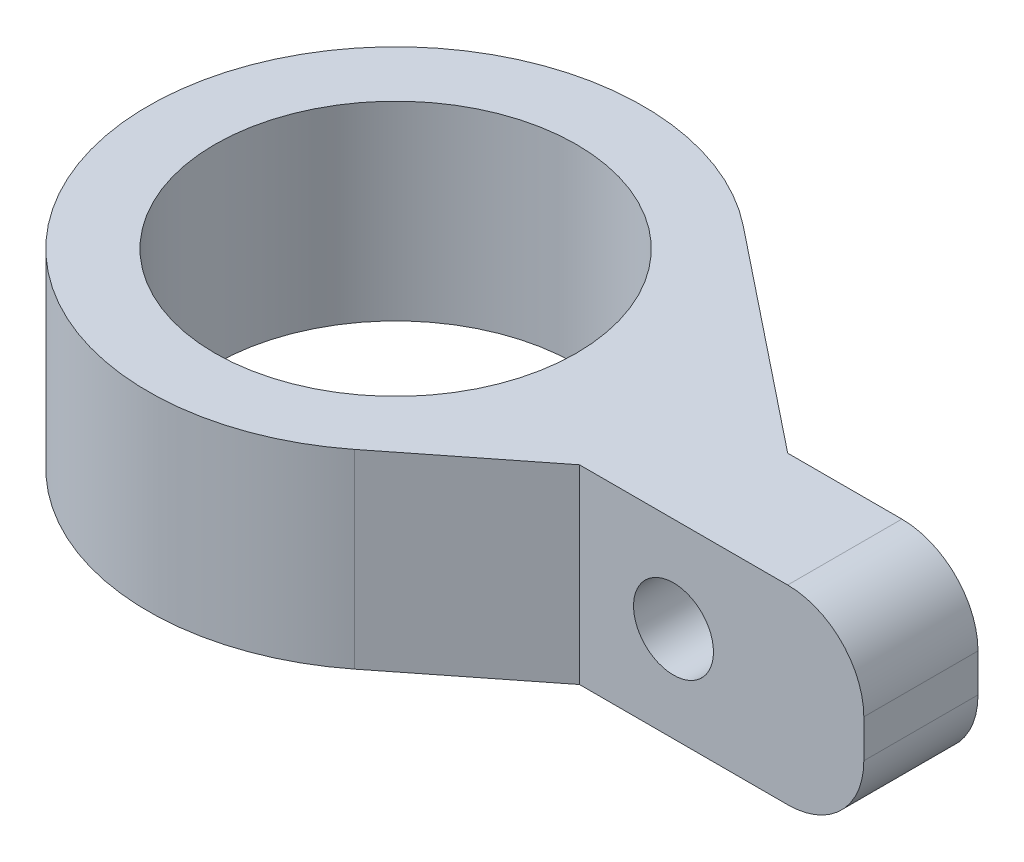
from build123d import *

# Parameters (mm, degrees)
SKETCH1_W           = 10
SKETCH1_H           = 5
BOSS_EXTRUDE1_DEPTH = 3
FILLET1_R           = 2
SKETCH3_R           = 6.5
BOSS_EXTRUDE2_DEPTH = 2.5
SKETCH4_R           = 4.75
CUT_EXTRUDE1_DEPTH  = 6
SKETCH7_R           = 1.05
CUT_EXTRUDE2_DEPTH  = 2
BOSS_EXTRUDE3_DEPTH = 5


with BuildPart() as part:
    # Sketch1 → Boss-Extrude1 (new body)
    with BuildSketch(Plane.XY):
        Rectangle(SKETCH1_W, SKETCH1_H)
    extrude(amount=BOSS_EXTRUDE1_DEPTH)

    # Fillet1
    fillet1_edges = [part.edges().sort_by_distance(p)[0] for p in [
        (5, 2.5, 1.5),
        (5, -2.5, 1.5),
    ]]
    fillet(fillet1_edges, radius=FILLET1_R)

    # Sketch7 → Cut-Extrude2 (cut)
    with BuildSketch(Plane.XY.offset(3)):
        Circle(SKETCH7_R)
    extrude(amount=-CUT_EXTRUDE2_DEPTH, mode=Mode.SUBTRACT)



with BuildPart() as body_2:
    # Sketch3 → Boss-Extrude2 (new body, symmetric)
    with BuildSketch(Plane(origin=(0, 0, 0), x_dir=(1, 0, 0), z_dir=(0, 1, 0))):
        with Locations((-9.8, -0.5)):
            Circle(SKETCH3_R)
    extrude(amount=BOSS_EXTRUDE2_DEPTH, both=True)

    # Sketch4 → Cut-Extrude1 (cut, through all)
    with BuildSketch(Plane.XZ.offset(2.5)):
        with Locations((-9.8, 0.5)):
            Circle(SKETCH4_R)
    extrude(amount=-CUT_EXTRUDE1_DEPTH, mode=Mode.SUBTRACT)


with BuildPart() as part_1:
    add(part.part)

    add(body_2.part)  # Boss-Extrude3 merges body 2
    # Sketch8 → Boss-Extrude3 (add)
    with BuildSketch(Plane.XZ.offset(2.5)):
        with BuildLine():
            Line((-5.77711019, 5.605522263), (-2.470394732, 3))
            Line((-2.470394732, 3), (-3.8, 3))
            ThreePointArc((-3.8, 3), (-4.621992024, 4.42915174), (-5.77711019, 5.605522263))
        make_face()
        with BuildLine():
            Line((-5.748087743, -4.582519755), (0, 0))
            Line((0, 0), (-3.319259302, 0))
            ThreePointArc((-3.319259302, 0), (-4.056824363, -2.543999606), (-5.748087743, -4.582519755))
        make_face()
    extrude(amount=-BOSS_EXTRUDE3_DEPTH)


solid = part_1.part
